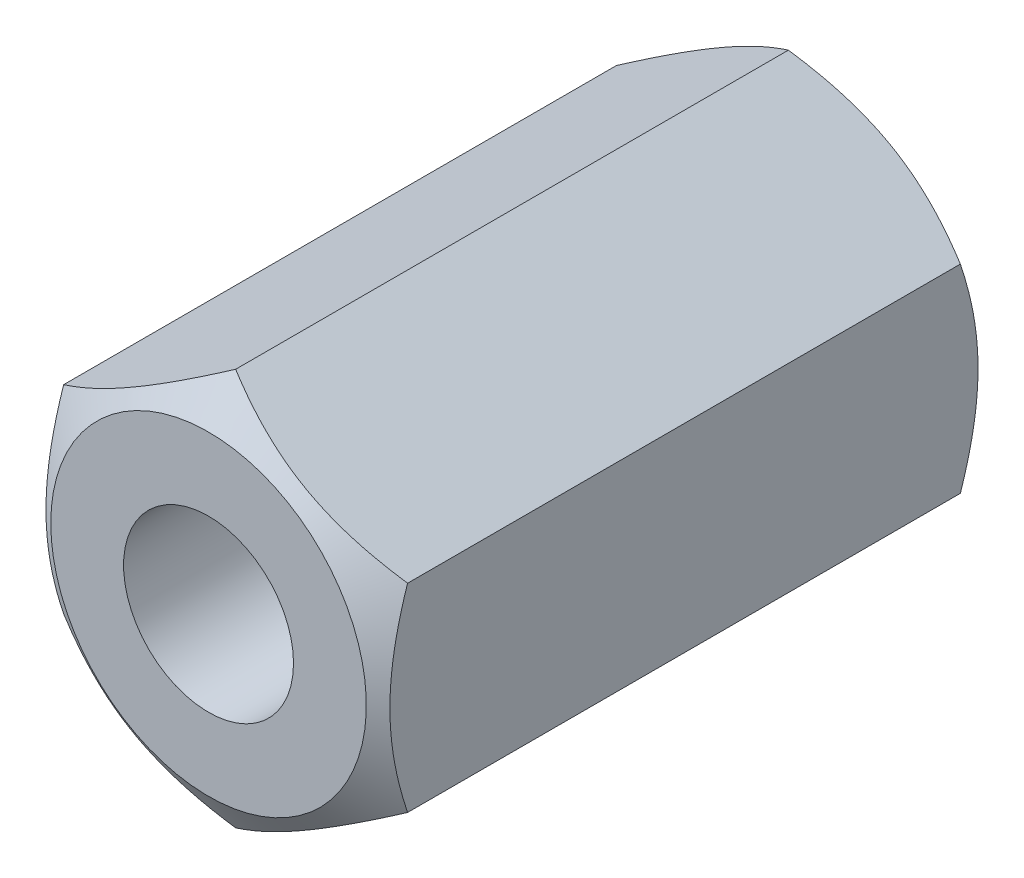
from build123d import *

# Parameters (mm, degrees)
BOSS_EXTRUDE1_DEPTH = 30
SKETCH2_R           = 4.2
CUT_EXTRUDE1_DEPTH  = 31


with BuildPart() as part:
    # Sketch1 → Boss-Extrude1 (new body)
    with BuildSketch(Plane.XY):
        Polygon((0, 9.814954576), (-8.5, 4.907477288), (-8.5, -4.907477288), (0, -9.814954576), (8.5, -4.907477288), (8.5, 4.907477288), align=None)
    extrude(amount=BOSS_EXTRUDE1_DEPTH)

    # Sketch2 → Cut-Extrude1 (cut, through all)
    with BuildSketch(Plane.XY.offset(30)):
        Circle(SKETCH2_R)
    extrude(amount=-CUT_EXTRUDE1_DEPTH, mode=Mode.SUBTRACT)

    # Sketch3 → Cut-Revolve1 (revolve, cut)
    with BuildSketch(Plane(origin=(0, 0, 0), x_dir=(0, 0, -1), z_dir=(1, 0, 0))):
        Polygon((-28.661748937, 9.814954576), (-30, 7.798581685), (-30, 9.814954576), align=None)
        Polygon((0, 7.798581685), (0, 9.814954576), (-1.338251063, 9.814954576), align=None)
    revolve(axis=Axis((0, 0, -5.872116431), (0, 0, 1)), mode=Mode.SUBTRACT)


solid = part.part
